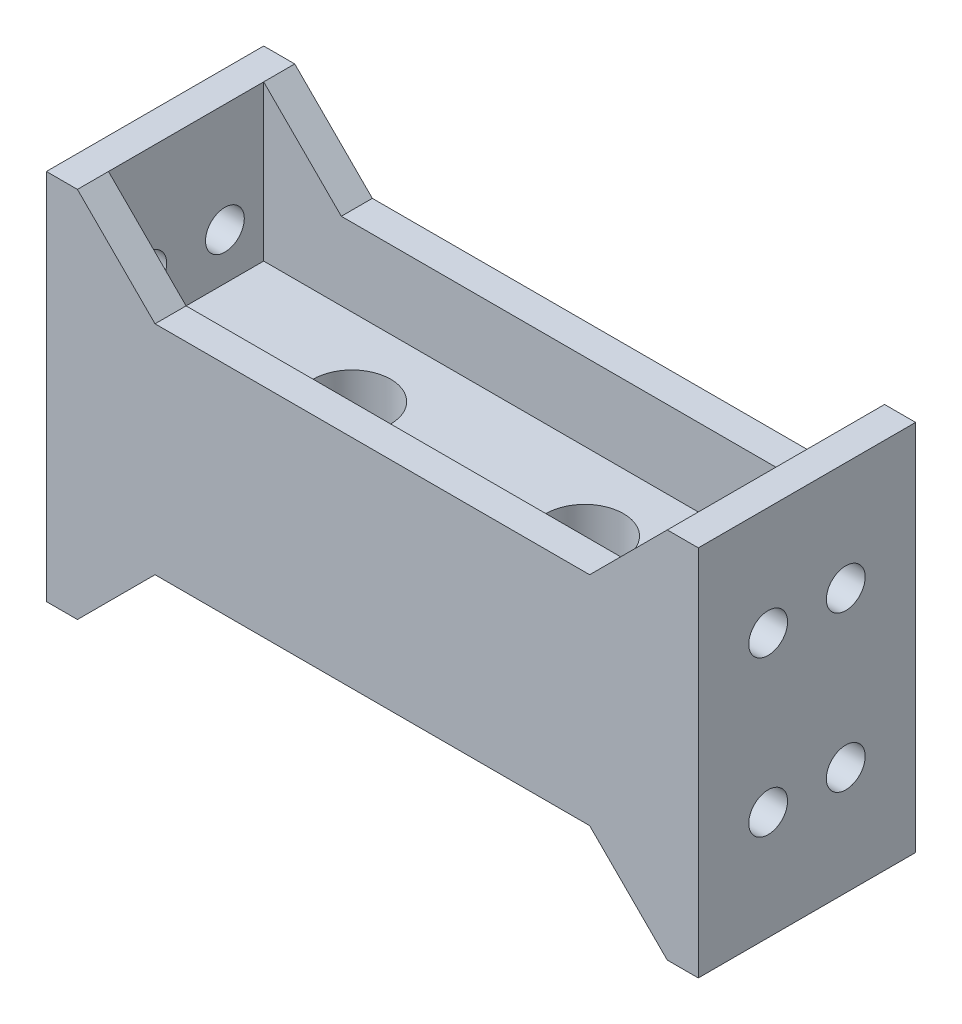
from build123d import *

# Parameters (mm, degrees)
SKETCH2_W               = 42
SKETCH2_H               = 14
BOSS_EXTRUDE1_DEPTH     = 4
SKETCH3_W               = 2
SKETCH3_H               = 14
BOSS_EXTRUDE2_DEPTH     = 10
BOSS_EXTRUDE3_DEPTH     = 2
SKETCH5_R               = 2.5
CUT_EXTRUDE1_DEPTH      = 11
CUT_EXTRUDE1_DEPTH_BACK = 5
SKETCH6_R               = 1.25
CUT_EXTRUDE2_DEPTH      = 2
SKETCH7_W               = 2
SKETCH7_H               = 14
BOSS_EXTRUDE4_DEPTH     = 10
SKETCH8_R               = 1.25
CUT_EXTRUDE3_DEPTH      = 10
BOSS_EXTRUDE5_DEPTH     = 2


with BuildPart() as part:
    # Sketch2 → Boss-Extrude1 (new body)
    with BuildSketch(Plane(origin=(0, 0, 0), x_dir=(1, 0, 0), z_dir=(0, 1, 0))):
        Rectangle(SKETCH2_W, SKETCH2_H)
    extrude(amount=BOSS_EXTRUDE1_DEPTH)

    # Sketch3 → Boss-Extrude2 (add)
    with BuildSketch(Plane.XZ):
        with Locations((-20, 0)):
            Rectangle(SKETCH3_W, SKETCH3_H)
        with Locations((20, 0)):
            Rectangle(SKETCH3_W, SKETCH3_H)
    extrude(amount=BOSS_EXTRUDE2_DEPTH)

    # Sketch4 → Boss-Extrude3 (add)
    with BuildSketch(Plane.XY.offset(7)):
        Polygon((-14, -5), (14, -5), (19, -10), (19, 0), (-19, 0), (-19, -10), align=None)
    boss_extrude3 = extrude(amount=-BOSS_EXTRUDE3_DEPTH)

    # Mirror1: Boss-Extrude3 across plane
    add(boss_extrude3.mirror(Plane.XY))

    # Sketch5 → Cut-Extrude1 (cut, two sides)
    with BuildSketch(Plane.XZ) as cut_extrude1_sk:
        with Locations((-8.319906625, 0)):
            Circle(SKETCH5_R)
        with Locations((6.680093375, 0)):
            Circle(SKETCH5_R)
    extrude(amount=CUT_EXTRUDE1_DEPTH, mode=Mode.SUBTRACT)
    extrude(cut_extrude1_sk.sketch, amount=-CUT_EXTRUDE1_DEPTH_BACK, mode=Mode.SUBTRACT)

    # Sketch6 → Cut-Extrude2 (cut)
    with BuildSketch(Plane(origin=(-19, 0, 0), x_dir=(0, 0, -1), z_dir=(1, 0, 0))):
        with Locations((-2.5, -3)):
            Circle(SKETCH6_R)
        with Locations((2.5, -3)):
            Circle(SKETCH6_R)
    cut_extrude2 = extrude(amount=-CUT_EXTRUDE2_DEPTH, mode=Mode.SUBTRACT)

    # Mirror2: Cut-Extrude2 across plane
    add(cut_extrude2.mirror(Plane(origin=(0, 0, 0), x_dir=(0, 0, 1), z_dir=(1, 0, 0))), mode=Mode.SUBTRACT)

    # Sketch7 → Boss-Extrude4 (add)
    with BuildSketch(Plane(origin=(0, 4, 0), x_dir=(1, 0, 0), z_dir=(0, 1, 0))):
        with Locations((-20, 0)):
            Rectangle(SKETCH7_W, SKETCH7_H)
        with Locations((20, 0)):
            Rectangle(SKETCH7_W, SKETCH7_H)
    extrude(amount=BOSS_EXTRUDE4_DEPTH)

    # Sketch8 → Cut-Extrude3 (cut)
    with BuildSketch(Plane(origin=(-19, 0, 0), x_dir=(0, 0, -1), z_dir=(1, 0, 0))):
        with Locations((-2.5, 7)):
            Circle(SKETCH8_R)
        with Locations((2.5, 7)):
            Circle(SKETCH8_R)
    cut_extrude3 = extrude(amount=-CUT_EXTRUDE3_DEPTH, mode=Mode.SUBTRACT)

    # Mirror3: Cut-Extrude3 across plane
    add(cut_extrude3.mirror(Plane(origin=(0, 0, 0), x_dir=(0, 0, 1), z_dir=(1, 0, 0))), mode=Mode.SUBTRACT)

    # Sketch9 → Boss-Extrude5 (add)
    with BuildSketch(Plane(origin=(0, 0, -7), x_dir=(-1, 0, 0), z_dir=(0, 0, -1))):
        Polygon((19, 14), (19, 4), (-19, 4), (-19, 14), (-14, 9), (14, 9), align=None)
    boss_extrude5 = extrude(amount=-BOSS_EXTRUDE5_DEPTH)

    # Mirror4: Boss-Extrude5 across plane
    add(boss_extrude5.mirror(Plane.XY))


solid = part.part
